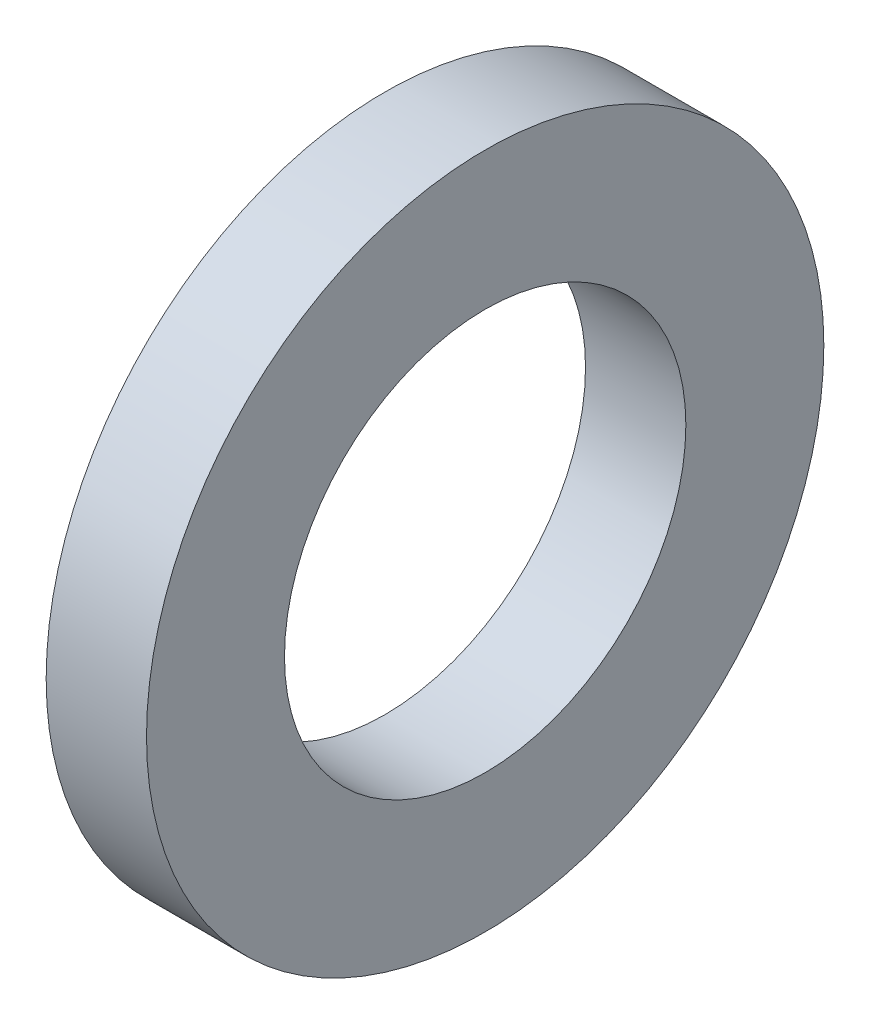
from build123d import *

# Parameters (mm, degrees)
SKETCH1_R           = 6.75
BOSS_EXTRUDE1_DEPTH = 2
SKETCH2_R           = 4
CUT_EXTRUDE1_DEPTH  = 3


with BuildPart() as part:
    # Sketch1 → Boss-Extrude1 (new body)
    with BuildSketch(Plane(origin=(0, 0, 0), x_dir=(0, 0, -1), z_dir=(1, 0, 0))):
        Circle(SKETCH1_R)
    extrude(amount=BOSS_EXTRUDE1_DEPTH)

    # Sketch2 → Cut-Extrude1 (cut, through all)
    with BuildSketch(Plane(origin=(2, 0, 0), x_dir=(0, 0, -1), z_dir=(1, 0, 0))):
        Circle(SKETCH2_R)
    extrude(amount=-CUT_EXTRUDE1_DEPTH, mode=Mode.SUBTRACT)


solid = part.part
